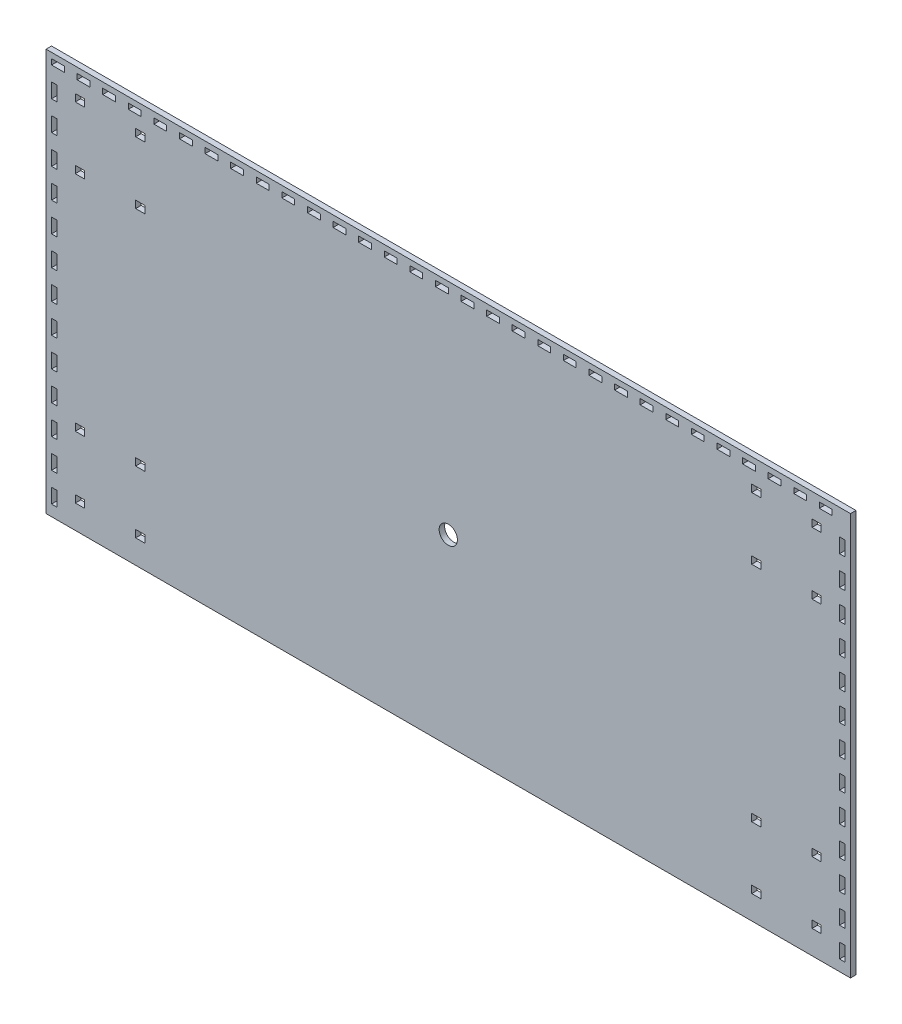
from build123d import *

# Parameters (mm, degrees)
ESQUISSE1_W             = 440
ESQUISSE1_H             = 220
BOSS_EXTRU_1_DEPTH      = 3
ESQUISSE2_R             = 5
ENL_V_MAT_EXTRU_1_DEPTH = 3
ESQUISSE3_W             = 5
ESQUISSE3_H             = 4
ENL_V_MAT_EXTRU_2_DEPTH = 3
ESQUISSE4_W             = 7
ESQUISSE4_H             = 3
ENL_V_MAT_EXTRU_3_DEPTH = 3
ESQUISSE5_W             = 3
ESQUISSE5_H             = 8
ENL_V_MAT_EXTRU_4_DEPTH = 3


with BuildPart() as part:
    # Esquisse1 → Boss.-Extru.1 (new body)
    with BuildSketch(Plane.XY):
        Rectangle(ESQUISSE1_W, ESQUISSE1_H)
    extrude(amount=BOSS_EXTRU_1_DEPTH)

    # Esquisse2 → Enlèv. mat.-Extru.1 (cut)
    with BuildSketch(Plane.XY.offset(3)):
        with Locations((0, -10)):
            Circle(ESQUISSE2_R)
    extrude(amount=-ENL_V_MAT_EXTRU_1_DEPTH, mode=Mode.SUBTRACT)

    # Esquisse3 → Enlèv. mat.-Extru.2 (cut)
    with BuildSketch(Plane.XY.offset(3)):
        with Locations((-201.5, 95)):
            Rectangle(ESQUISSE3_W, ESQUISSE3_H)
        with Locations((-168.5, 95)):
            Rectangle(ESQUISSE3_W, ESQUISSE3_H)
        with Locations((-168.5, 61)):
            Rectangle(ESQUISSE3_W, ESQUISSE3_H)
        with Locations((-201.5, 61)):
            Rectangle(ESQUISSE3_W, ESQUISSE3_H)
        with Locations((168.5, 61)):
            Rectangle(ESQUISSE3_W, ESQUISSE3_H)
        with Locations((201.5, 61)):
            Rectangle(ESQUISSE3_W, ESQUISSE3_H)
        with Locations((168.5, 95)):
            Rectangle(ESQUISSE3_W, ESQUISSE3_H)
        with Locations((201.5, 95)):
            Rectangle(ESQUISSE3_W, ESQUISSE3_H)
        with Locations((-168.5, -95)):
            Rectangle(ESQUISSE3_W, ESQUISSE3_H)
        with Locations((-201.5, -95)):
            Rectangle(ESQUISSE3_W, ESQUISSE3_H)
        with Locations((-168.5, -61)):
            Rectangle(ESQUISSE3_W, ESQUISSE3_H)
        with Locations((-201.5, -61)):
            Rectangle(ESQUISSE3_W, ESQUISSE3_H)
        with Locations((201.5, -95)):
            Rectangle(ESQUISSE3_W, ESQUISSE3_H)
        with Locations((168.5, -95)):
            Rectangle(ESQUISSE3_W, ESQUISSE3_H)
        with Locations((201.5, -61)):
            Rectangle(ESQUISSE3_W, ESQUISSE3_H)
        with Locations((168.5, -61)):
            Rectangle(ESQUISSE3_W, ESQUISSE3_H)
    extrude(amount=-ENL_V_MAT_EXTRU_2_DEPTH, mode=Mode.SUBTRACT)

    # Esquisse4 → Enlèv. mat.-Extru.3 (cut)
    with BuildSketch(Plane.XY.offset(3)):
        with Locations((-213.5, 105.5)):
            Rectangle(ESQUISSE4_W, ESQUISSE4_H)
        with Locations((-199.5, 105.5)):
            Rectangle(ESQUISSE4_W, ESQUISSE4_H)
        with Locations((-185.5, 105.5)):
            Rectangle(ESQUISSE4_W, ESQUISSE4_H)
        with Locations((-171.5, 105.5)):
            Rectangle(ESQUISSE4_W, ESQUISSE4_H)
        with Locations((-157.5, 105.5)):
            Rectangle(ESQUISSE4_W, ESQUISSE4_H)
        with Locations((-143.5, 105.5)):
            Rectangle(ESQUISSE4_W, ESQUISSE4_H)
        with Locations((-129.5, 105.5)):
            Rectangle(ESQUISSE4_W, ESQUISSE4_H)
        with Locations((-115.5, 105.5)):
            Rectangle(ESQUISSE4_W, ESQUISSE4_H)
        with Locations((-101.5, 105.5)):
            Rectangle(ESQUISSE4_W, ESQUISSE4_H)
        with Locations((-87.5, 105.5)):
            Rectangle(ESQUISSE4_W, ESQUISSE4_H)
        with Locations((-73.5, 105.5)):
            Rectangle(ESQUISSE4_W, ESQUISSE4_H)
        with Locations((-59.5, 105.5)):
            Rectangle(ESQUISSE4_W, ESQUISSE4_H)
        with Locations((-45.5, 105.5)):
            Rectangle(ESQUISSE4_W, ESQUISSE4_H)
        with Locations((-31.5, 105.5)):
            Rectangle(ESQUISSE4_W, ESQUISSE4_H)
        with Locations((-17.5, 105.5)):
            Rectangle(ESQUISSE4_W, ESQUISSE4_H)
        with Locations((-3.5, 105.5)):
            Rectangle(ESQUISSE4_W, ESQUISSE4_H)
        with Locations((10.5, 105.5)):
            Rectangle(ESQUISSE4_W, ESQUISSE4_H)
        with Locations((24.5, 105.5)):
            Rectangle(ESQUISSE4_W, ESQUISSE4_H)
        with Locations((38.5, 105.5)):
            Rectangle(ESQUISSE4_W, ESQUISSE4_H)
        with Locations((52.5, 105.5)):
            Rectangle(ESQUISSE4_W, ESQUISSE4_H)
        with Locations((66.5, 105.5)):
            Rectangle(ESQUISSE4_W, ESQUISSE4_H)
        with Locations((80.5, 105.5)):
            Rectangle(ESQUISSE4_W, ESQUISSE4_H)
        with Locations((94.5, 105.5)):
            Rectangle(ESQUISSE4_W, ESQUISSE4_H)
        with Locations((108.5, 105.5)):
            Rectangle(ESQUISSE4_W, ESQUISSE4_H)
        with Locations((122.5, 105.5)):
            Rectangle(ESQUISSE4_W, ESQUISSE4_H)
        with Locations((136.5, 105.5)):
            Rectangle(ESQUISSE4_W, ESQUISSE4_H)
        with Locations((150.5, 105.5)):
            Rectangle(ESQUISSE4_W, ESQUISSE4_H)
        with Locations((164.5, 105.5)):
            Rectangle(ESQUISSE4_W, ESQUISSE4_H)
        with Locations((178.5, 105.5)):
            Rectangle(ESQUISSE4_W, ESQUISSE4_H)
        with Locations((192.5, 105.5)):
            Rectangle(ESQUISSE4_W, ESQUISSE4_H)
        with Locations((206.5, 105.5)):
            Rectangle(ESQUISSE4_W, ESQUISSE4_H)
    extrude(amount=-ENL_V_MAT_EXTRU_3_DEPTH, mode=Mode.SUBTRACT)

    # Esquisse5 → Enlèv. mat.-Extru.4 (cut)
    with BuildSketch(Plane.XY.offset(3)):
        with Locations((-215.5, -100)):
            Rectangle(ESQUISSE5_W, ESQUISSE5_H)
        with Locations((-215.5, -84)):
            Rectangle(ESQUISSE5_W, ESQUISSE5_H)
        with Locations((-215.5, -68)):
            Rectangle(ESQUISSE5_W, ESQUISSE5_H)
        with Locations((-215.5, -52)):
            Rectangle(ESQUISSE5_W, ESQUISSE5_H)
        with Locations((-215.5, -36)):
            Rectangle(ESQUISSE5_W, ESQUISSE5_H)
        with Locations((-215.5, -20)):
            Rectangle(ESQUISSE5_W, ESQUISSE5_H)
        with Locations((-215.5, -4)):
            Rectangle(ESQUISSE5_W, ESQUISSE5_H)
        with Locations((-215.5, 12)):
            Rectangle(ESQUISSE5_W, ESQUISSE5_H)
        with Locations((-215.5, 28)):
            Rectangle(ESQUISSE5_W, ESQUISSE5_H)
        with Locations((-215.5, 44)):
            Rectangle(ESQUISSE5_W, ESQUISSE5_H)
        with Locations((-215.5, 60)):
            Rectangle(ESQUISSE5_W, ESQUISSE5_H)
        with Locations((-215.5, 76)):
            Rectangle(ESQUISSE5_W, ESQUISSE5_H)
        with Locations((-215.5, 92)):
            Rectangle(ESQUISSE5_W, ESQUISSE5_H)
        with Locations((215.5, 92)):
            Rectangle(ESQUISSE5_W, ESQUISSE5_H)
        with Locations((215.5, 76)):
            Rectangle(ESQUISSE5_W, ESQUISSE5_H)
        with Locations((215.5, 60)):
            Rectangle(ESQUISSE5_W, ESQUISSE5_H)
        with Locations((215.5, 44)):
            Rectangle(ESQUISSE5_W, ESQUISSE5_H)
        with Locations((215.5, 28)):
            Rectangle(ESQUISSE5_W, ESQUISSE5_H)
        with Locations((215.5, 12)):
            Rectangle(ESQUISSE5_W, ESQUISSE5_H)
        with Locations((215.5, -4)):
            Rectangle(ESQUISSE5_W, ESQUISSE5_H)
        with Locations((215.5, -20)):
            Rectangle(ESQUISSE5_W, ESQUISSE5_H)
        with Locations((215.5, -36)):
            Rectangle(ESQUISSE5_W, ESQUISSE5_H)
        with Locations((215.5, -52)):
            Rectangle(ESQUISSE5_W, ESQUISSE5_H)
        with Locations((215.5, -68)):
            Rectangle(ESQUISSE5_W, ESQUISSE5_H)
        with Locations((215.5, -84)):
            Rectangle(ESQUISSE5_W, ESQUISSE5_H)
        with Locations((215.5, -100)):
            Rectangle(ESQUISSE5_W, ESQUISSE5_H)
    extrude(amount=-ENL_V_MAT_EXTRU_4_DEPTH, mode=Mode.SUBTRACT)


solid = part.part
